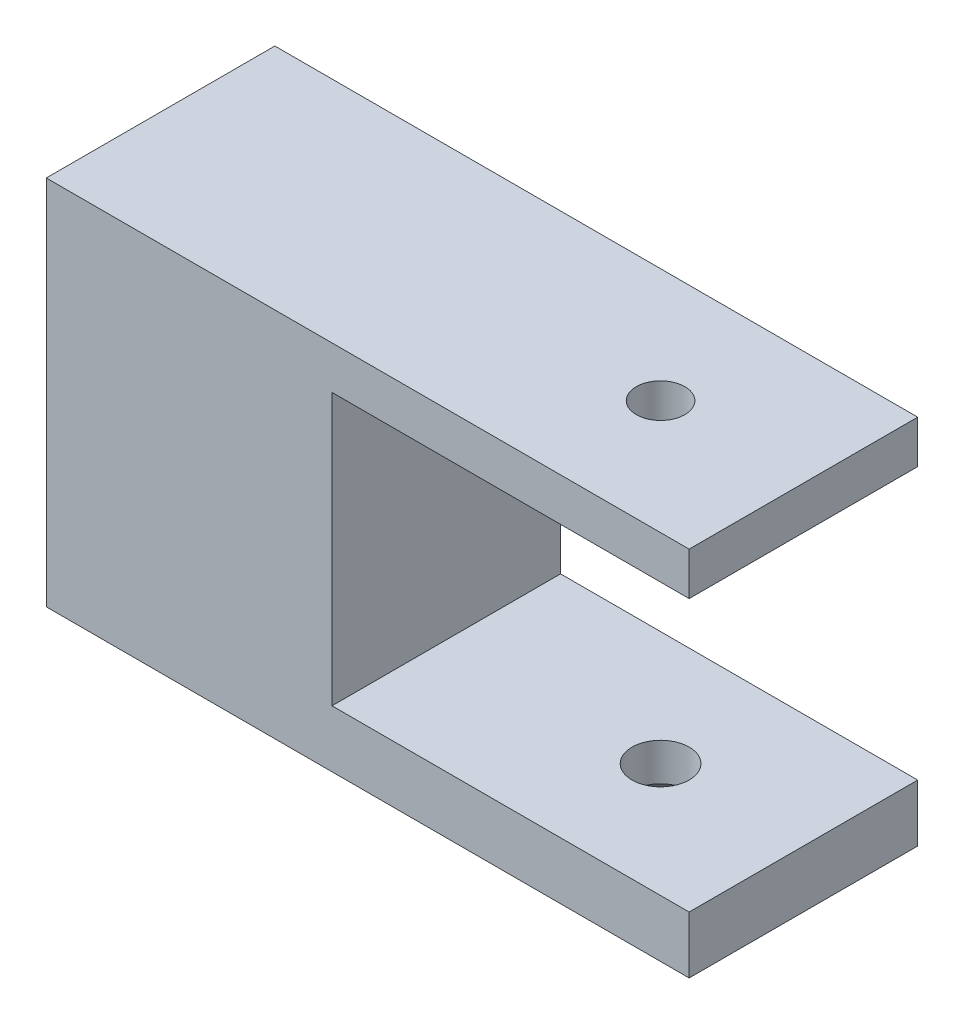
from build123d import *

# Parameters (mm, degrees)
SALIENTE_EXTRUIR1_DEPTH                              = 16
CROQUIS2_R                                           = 6.2
CORTAR_EXTRUIR1_DEPTH                                = 17
CROQUIS3_R                                           = 2
CORTAR_EXTRUIR2_DEPTH                                = 4
REFRENTADO_PARA_TORNILLO_TAP_N_CON_CABEZ_D           = 3.4
REFRENTADO_PARA_TORNILLO_TAP_N_CON_CABEZ_CSINK_D     = 6.72
REFRENTADO_PARA_TORNILLO_TAP_N_CON_CABEZ_CSINK_ANGLE = 90
CROQUIS6_R                                           = 3.5
CORTAR_EXTRUIR3_DEPTH                                = 10


with BuildPart() as part:
    # Croquis1 → Saliente-Extruir1 (new body)
    with BuildSketch(Plane.XY):
        Polygon((-121.785392746, 32.439983022), (-153.785392746, 32.439983022), (-166.785392746, 32.439983022), (-166.785392746, 6.439983022), (-121.785392746, 6.439983022), (-121.785392746, 10.439983022), (-146.785392746, 10.439983022), (-146.785392746, 29.439983022), (-121.785392746, 29.439983022), align=None)
    extrude(amount=SALIENTE_EXTRUIR1_DEPTH)

    # Croquis2 → Cortar-Extruir1 (cut)
    with BuildSketch(Plane.ZY.offset(166.785392746)):
        with Locations((8, 19.439983022)):
            Circle(CROQUIS2_R)
    extrude(amount=-CORTAR_EXTRUIR1_DEPTH, mode=Mode.SUBTRACT)

    # Croquis3 → Cortar-Extruir2 (cut)
    with BuildSketch(Plane.XZ.offset(-6.439983022)):
        with Locations((-131.785392746, 8)):
            Circle(CROQUIS3_R)
    extrude(amount=-CORTAR_EXTRUIR2_DEPTH, mode=Mode.SUBTRACT)

    # Refrentado para tornillo tapón con cabeza plana de clavija de M31 (through all)
    with Locations(Plane(origin=(0, 6.439983022, 0), x_dir=(-1, 0, 0), z_dir=(0, -1, 0))):
        with Locations((131.785392746, -8)):
            CounterSinkHole(REFRENTADO_PARA_TORNILLO_TAP_N_CON_CABEZ_D / 2, REFRENTADO_PARA_TORNILLO_TAP_N_CON_CABEZ_CSINK_D / 2, counter_sink_angle=REFRENTADO_PARA_TORNILLO_TAP_N_CON_CABEZ_CSINK_ANGLE)

    # Croquis6 → Cortar-Extruir3 (cut)
    with BuildSketch(Plane(origin=(0, 0, 0), x_dir=(-1, 0, 0), z_dir=(0, 0, -1))):
        with Locations((152.785392746, 19.439983022)):
            Circle(CROQUIS6_R)
    extrude(amount=-CORTAR_EXTRUIR3_DEPTH, mode=Mode.SUBTRACT)


solid = part.part
